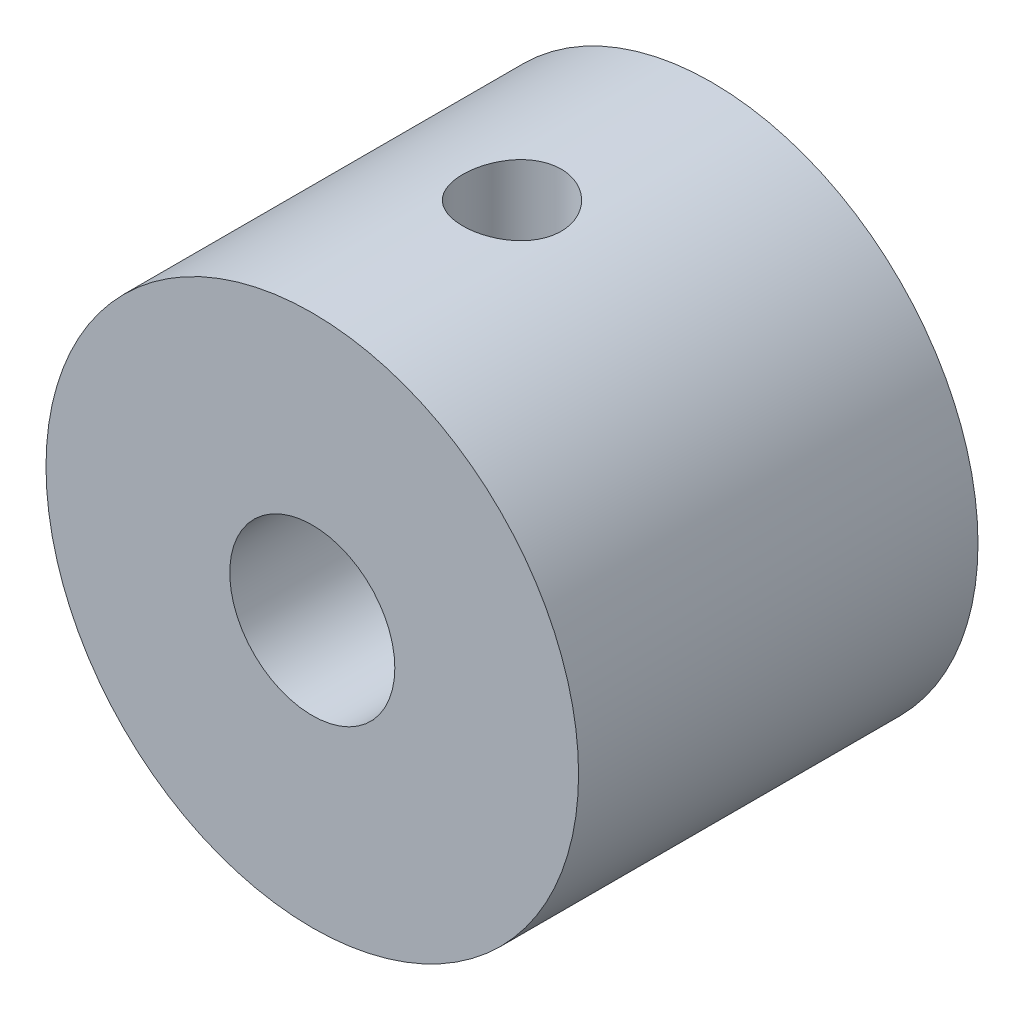
from build123d import *

# Parameters (mm, degrees)
SKETCH_1_R          = 10
SKETCH_1_R_2        = 3.1
EXTRUDE_1_DEPTH     = 15
SKETCH_2_R          = 1.85
CUT_EXTRUDE_1_DEPTH = 11


with BuildPart() as part:
    # 스케치1 → 보스-돌출1 (new body)
    with BuildSketch(Plane.XY):
        Circle(SKETCH_1_R)
        Circle(SKETCH_1_R_2, mode=Mode.SUBTRACT)
    extrude(amount=EXTRUDE_1_DEPTH)

    # 스케치2 → 컷-돌출1 (cut, through all)
    with BuildSketch(Plane(origin=(0, 0, 0), x_dir=(1, 0, 0), z_dir=(0, 1, 0))):
        with Locations((0, -7.5)):
            Circle(SKETCH_2_R)
    extrude(amount=CUT_EXTRUDE_1_DEPTH, mode=Mode.SUBTRACT)


solid = part.part
